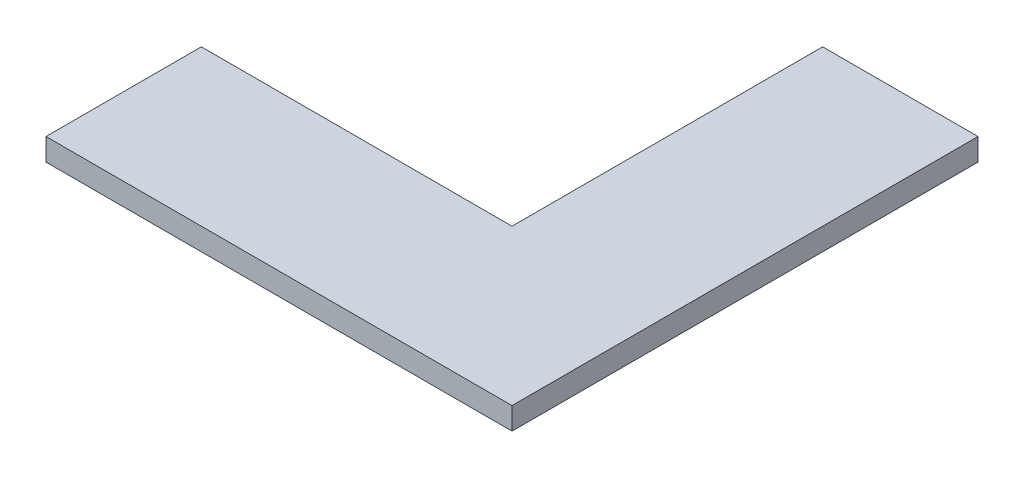
from build123d import *

# Parameters (mm, degrees)
BOSS_EXTRUDE1_DEPTH = 10


with BuildPart() as part:
    # Sketch1 → Boss-Extrude1 (new body)
    with BuildSketch(Plane(origin=(0, 0, 0), x_dir=(1, 0, 0), z_dir=(0, 1, 0))):
        Polygon((35, 105), (105, 105), (105, -105), (-105, -105), (-105, -35), (35, -35), align=None)
    extrude(amount=BOSS_EXTRUDE1_DEPTH)


solid = part.part
